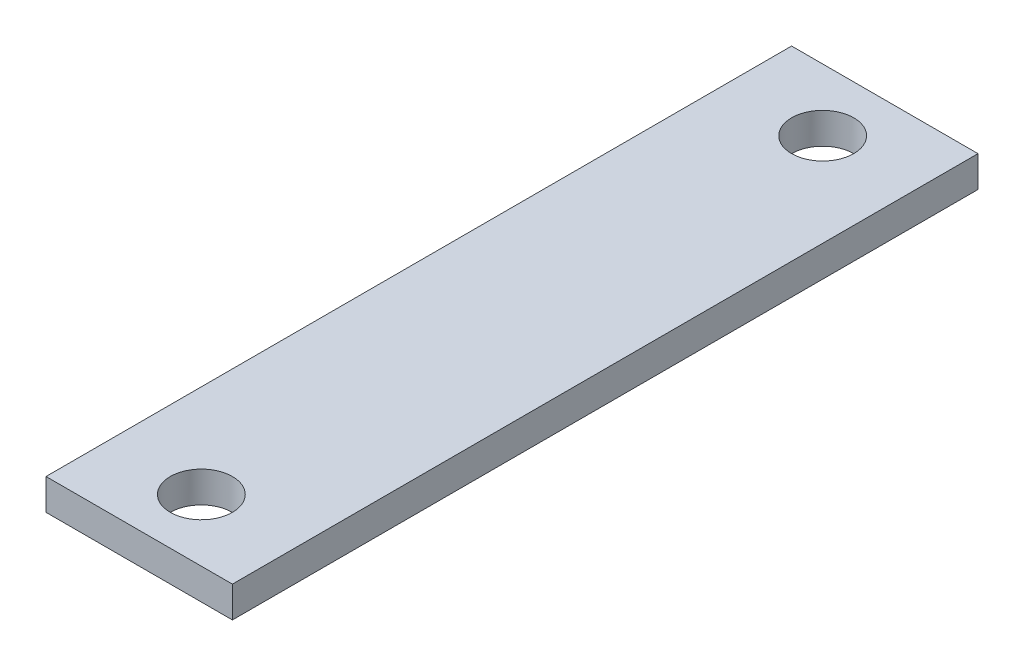
from build123d import *

# Parameters (mm, degrees)
SKETCH1_W           = 3
SKETCH1_H           = 12
BOSS_EXTRUDE1_DEPTH = 0.5
SKETCH2_R           = 0.5
CUT_EXTRUDE1_DEPTH  = 1


with BuildPart() as part:
    # Sketch1 → Boss-Extrude1 (new body)
    with BuildSketch(Plane(origin=(0, 0, 0), x_dir=(1, 0, 0), z_dir=(0, 1, 0))):
        with Locations((0, 2.768181818)):
            Rectangle(SKETCH1_W, SKETCH1_H)
    extrude(amount=BOSS_EXTRUDE1_DEPTH)

    # Sketch2 → Cut-Extrude1 (cut)
    with BuildSketch(Plane(origin=(0, 0.5, 0), x_dir=(1, 0, 0), z_dir=(0, 1, 0))):
        with Locations((0, 7.768181818)):
            Circle(SKETCH2_R)
        with Locations((0, -2.231818182)):
            Circle(SKETCH2_R)
    extrude(amount=-CUT_EXTRUDE1_DEPTH, mode=Mode.SUBTRACT)


solid = part.part
